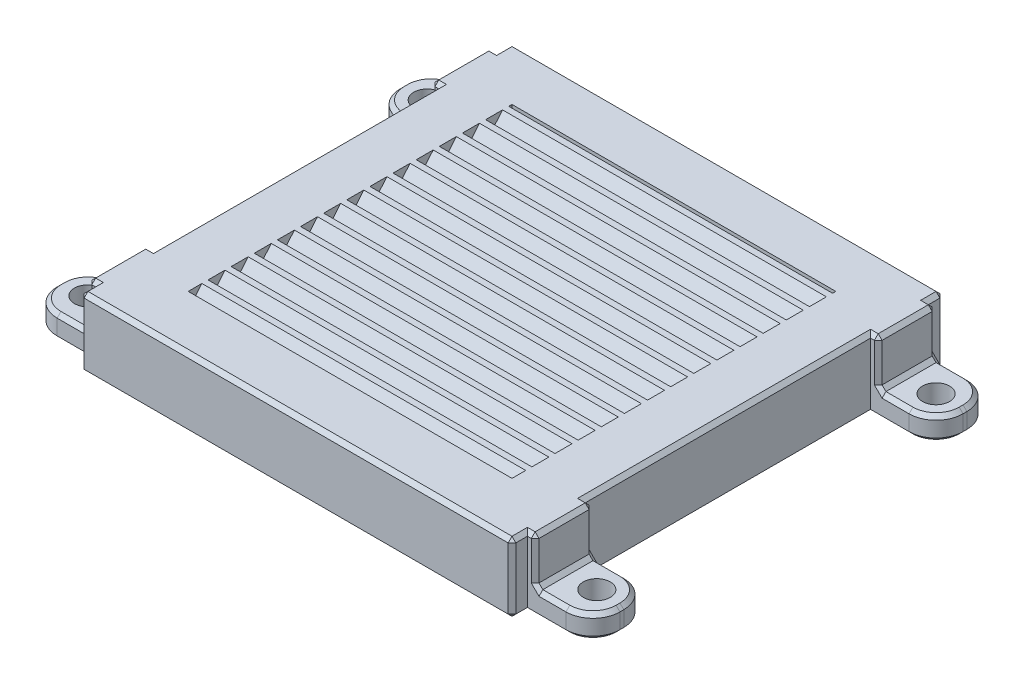
from build123d import *

# Parameters (mm, degrees)
CROQUIS1_W              = 52
CROQUIS1_H              = 52
CROQUIS1_W_2            = 42
CROQUIS1_H_2            = 42
SALIENTE_EXTRUIR1_DEPTH = 2
SALIENTE_EXTRUIR6_DEPTH = 42
CROQUIS4_W              = 7.5
CROQUIS4_H              = 2
SALIENTE_EXTRUIR3_DEPTH = 3
CROQUIS5_W              = 3
CROQUIS5_H              = 7.5
SALIENTE_EXTRUIR4_DEPTH = 7
CROQUIS6_W              = 7.5
CROQUIS6_H              = 3
SALIENTE_EXTRUIR5_DEPTH = 7.5
CROQUIS7_R              = 1.75
CORTAR_EXTRUIR1_DEPTH   = 7.5
CROQUIS9_W              = 56
CROQUIS9_H              = 56
CROQUIS9_W_2            = 52
CROQUIS9_H_2            = 52
SALIENTE_EXTRUIR7_DEPTH = 9
REDONDEO1_R             = 3.5
CHAFL_N1_SIZE           = 0.5


with BuildPart() as part:
    # Croquis1 → Saliente-Extruir1 (new body)
    with BuildSketch(Plane(origin=(0, 0, 0), x_dir=(1, 0, 0), z_dir=(0, 1, 0))):
        Rectangle(CROQUIS1_W, CROQUIS1_H)
        Rectangle(CROQUIS1_W_2, CROQUIS1_H_2, mode=Mode.SUBTRACT)
    extrude(amount=SALIENTE_EXTRUIR1_DEPTH)

    # Croquis8 → Saliente-Extruir6 (add)
    with BuildSketch(Plane(origin=(-21, 0, 0), x_dir=(0, 0, -1), z_dir=(1, 0, 0))):
        Polygon((-20.9, 0), (-19.221800738, 2), (-18.421800738, 2), (-20.1, 0), align=None)
        Polygon((-17.1, 0), (-17.9, 0), (-16.221800738, 2), (-15.421800738, 2), align=None)
        Polygon((-14.1, 0), (-14.9, 0), (-13.221800738, 2), (-12.421800738, 2), align=None)
        Polygon((-11.1, 0), (-11.9, 0), (-10.221800738, 2), (-9.421800738, 2), align=None)
        Polygon((-8.1, 0), (-8.9, 0), (-7.221800738, 2), (-6.421800738, 2), align=None)
        Polygon((-5.1, 0), (-5.9, 0), (-4.221800738, 2), (-3.421800738, 2), align=None)
        Polygon((-2.1, 0), (-2.9, 0), (-1.221800738, 2), (-0.421800738, 2), align=None)
        Polygon((0.9, 0), (0.1, 0), (1.778199262, 2), (2.578199262, 2), align=None)
        Polygon((3.9, 0), (3.1, 0), (4.778199262, 2), (5.578199262, 2), align=None)
        Polygon((6.9, 0), (6.1, 0), (7.778199262, 2), (8.578199262, 2), align=None)
        Polygon((9.9, 0), (9.1, 0), (10.778199262, 2), (11.578199262, 2), align=None)
        Polygon((12.9, 0), (12.1, 0), (13.778199262, 2), (14.578199262, 2), align=None)
        Polygon((15.9, 0), (15.1, 0), (16.778199262, 2), (17.578199262, 2), align=None)
        Polygon((18.9, 0), (18.1, 0), (19.778199262, 2), (20.578199262, 2), align=None)
    extrude(amount=SALIENTE_EXTRUIR6_DEPTH)

    # Croquis4 → Saliente-Extruir3 (add)
    with BuildSketch(Plane(origin=(26, 0, 0), x_dir=(0, 0, -1), z_dir=(1, 0, 0))):
        with Locations((-22.25, 1)):
            Rectangle(CROQUIS4_W, CROQUIS4_H)
        with Locations((22.25, 1)):
            Rectangle(CROQUIS4_W, CROQUIS4_H)
    saliente_extruir3 = extrude(amount=SALIENTE_EXTRUIR3_DEPTH)

    # Croquis5 → Saliente-Extruir4 (add)
    with BuildSketch(Plane.XZ):
        with Locations((27.5, 22.25)):
            Rectangle(CROQUIS5_W, CROQUIS5_H)
        with Locations((27.5, -22.25)):
            Rectangle(CROQUIS5_W, CROQUIS5_H)
    saliente_extruir4 = extrude(amount=SALIENTE_EXTRUIR4_DEPTH)

    # Croquis6 → Saliente-Extruir5 (add)
    with BuildSketch(Plane(origin=(29, 0, 0), x_dir=(0, 0, -1), z_dir=(1, 0, 0))):
        with Locations((-22.25, -5.5)):
            Rectangle(CROQUIS6_W, CROQUIS6_H)
        with Locations((22.25, -5.5)):
            Rectangle(CROQUIS6_W, CROQUIS6_H)
    saliente_extruir5 = extrude(amount=SALIENTE_EXTRUIR5_DEPTH)

    # Croquis7 → Cortar-Extruir1 (cut)
    with BuildSketch(Plane(origin=(0, -4, 0), x_dir=(1, 0, 0), z_dir=(0, 1, 0))):
        with Locations((33, -22)):
            Circle(CROQUIS7_R)
        with Locations((33, 22)):
            Circle(CROQUIS7_R)
    cortar_extruir1 = extrude(amount=-CORTAR_EXTRUIR1_DEPTH, mode=Mode.SUBTRACT)

    # Simetría1: Saliente-Extruir3, Saliente-Extruir4, Saliente-Extruir5, Cortar-Extruir1 across plane
    add(saliente_extruir3.mirror(Plane(origin=(0, 0, 0), x_dir=(0, 0, 1), z_dir=(1, 0, 0))))
    add(saliente_extruir4.mirror(Plane(origin=(0, 0, 0), x_dir=(0, 0, 1), z_dir=(1, 0, 0))))
    add(saliente_extruir5.mirror(Plane(origin=(0, 0, 0), x_dir=(0, 0, 1), z_dir=(1, 0, 0))))
    add(cortar_extruir1.mirror(Plane(origin=(0, 0, 0), x_dir=(0, 0, 1), z_dir=(1, 0, 0))), mode=Mode.SUBTRACT)

    # Croquis9 → Saliente-Extruir7 (add)
    with BuildSketch(Plane(origin=(0, 2, 0), x_dir=(1, 0, 0), z_dir=(0, 1, 0))):
        Rectangle(CROQUIS9_W, CROQUIS9_H)
        Rectangle(CROQUIS9_W_2, CROQUIS9_H_2, mode=Mode.SUBTRACT)
    extrude(amount=-SALIENTE_EXTRUIR7_DEPTH)

    # Redondeo1
    redondeo1_edges = [part.edges().sort_by_distance(p)[0] for p in [
        (36.5, -5.5, 26),
        (36.5, -5.5, 18.5),
        (36.5, -5.5, -18.5),
        (36.5, -5.5, -26),
        (-36.5, -5.5, 26),
        (-36.5, -5.5, 18.5),
        (-36.5, -5.5, -18.5),
        (-36.5, -5.5, -26),
    ]]
    fillet(redondeo1_edges, radius=REDONDEO1_R)

    # Chaflán1
    chafl_n1_edges = [part.edges().sort_by_distance(p)[0] for p in [
        (-28.5, 2, 26),
        (28.5, 2, 18.5),
        (29, -1, 26),
        (29, 2, 22.25),
        (28.5, 2, -18.5),
        (29, 2, -22.25),
        (29, -1, -18.5),
        (26, -7, 0),
        (29, -1, 18.5),
        (29, -4, 22.25),
        (29, -1, -26),
        (29, -4, -22.25),
        (31.25, -7, 22),
        (31.25, -7, -22),
        (-29, -1, 26),
        (-29, 2, 22.25),
        (-28.5, 2, 18.5),
        (-29, -1, -18.5),
        (-29, 2, -22.25),
        (-28.5, 2, -18.5),
        (-26, -7, 0),
        (-29, -1, 18.5),
        (-29, -4, 22.25),
        (-29, -1, -26),
        (-29, -4, -22.25),
        (-31.25, -7, 22),
        (-31.25, -7, -22),
        (-30.5, -7, -26),
        (-30.5, -7, 18.5),
        (30.5, -7, -26),
        (30.5, -7, 18.5),
        (28.5, 2, 26),
        (-28.5, 2, -26),
        (28, -2.5, -28),
        (28, 2, -27),
        (0, 2, -28),
        (-28, 2, -27),
        (-28, 2, 27),
        (0, 2, 28),
        (28, 2, 27),
        (28, 2, 0),
        (28, -7, -27),
        (-28, -7, -27),
        (0, -7, -28),
        (-28, -7, 27),
        (28, -7, 27),
        (0, -7, 28),
        (28, -7, 0),
        (-28, -2.5, 28),
        (28, -2.5, 28),
        (-28, 2, 0),
        (0, -7, 26),
        (0, -7, -26),
        (-28, -7, 0),
        (36.5, -7, -22.25),
        (36.5, -4, -22.25),
        (31, -4, -18.5),
        (31, -4, -26),
        (35.474873734, -4, -19.525126266),
        (35.474873734, -4, -24.974873734),
        (30.5, -7, -18.5),
        (36.5, -7, 22.25),
        (30.5, -7, 26),
        (-30.5, -7, 26),
        (-36.5, -7, 22.25),
        (-30.5, -7, -18.5),
        (-36.5, -7, -22.25),
        (-35.474873734, -7, 24.974873734),
        (-35.474873734, -7, 19.525126266),
        (-35.474873734, -7, -24.974873734),
        (-35.474873734, -7, -19.525126266),
        (35.474873734, -7, 24.974873734),
        (35.474873734, -7, 19.525126266),
        (35.474873734, -7, -19.525126266),
        (35.474873734, -7, -24.974873734),
        (36.5, -4, 22.25),
        (31, -4, 26),
        (31, -4, 18.5),
        (35.474873734, -4, 24.974873734),
        (35.474873734, -4, 19.525126266),
        (-31, -4, -18.5),
        (-36.5, -4, -22.25),
        (-31, -4, -26),
        (-35.474873734, -4, -24.974873734),
        (-35.474873734, -4, -19.525126266),
        (-31, -4, 18.5),
        (-36.5, -4, 22.25),
        (-31, -4, 26),
        (-35.474873734, -4, 24.974873734),
        (-35.474873734, -4, 19.525126266),
        (28.5, 2, -26),
    ]]
    chamfer(chafl_n1_edges, length=CHAFL_N1_SIZE)


solid = part.part
